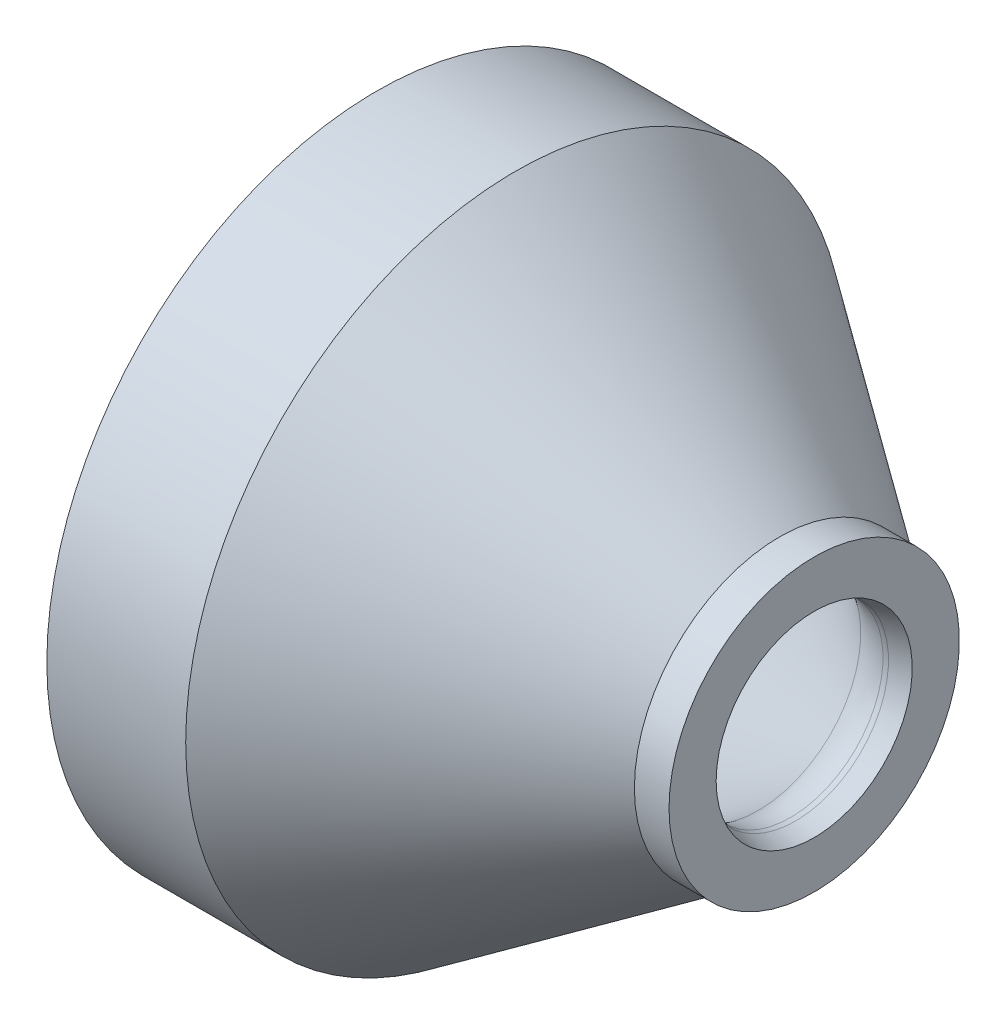
from build123d import *


with BuildPart() as part:
    # Sketch1 → Revolve1 (revolve)
    with BuildSketch(Plane.XY):
        with BuildLine():
            Line((18.706441928, 44.45), (0, 44.45))
            Line((0, 44.45), (0, 41.275))
            Line((0, 41.275), (12.7, 41.275))
            Line((12.7, 41.275), (12.7, 38.1))
            ThreePointArc((12.7, 38.1), (16.518963654, 37.512205275), (19.984420742, 35.803230962))
            Line((19.984420742, 35.803230962), (51.37392791, 13.824061423))
            ThreePointArc((51.37392791, 13.824061423), (53.453202163, 12.798676835), (55.744580355, 12.446))
            ThreePointArc((55.744580355, 12.446), (56.076116883, 12.467730052), (56.40198073, 12.532548401))
            Line((56.40198073, 12.532548401), (58.922800414, 13.208))
            Line((58.922800414, 13.208), (58.922800414, 19.558))
            Line((58.922800414, 19.558), (54.255902112, 19.558))
            Line((54.255902112, 19.558), (18.706441928, 44.45))
        make_face()
    revolve(axis=Axis((0, 0, 0), (1, 0, 0)))


solid = part.part
